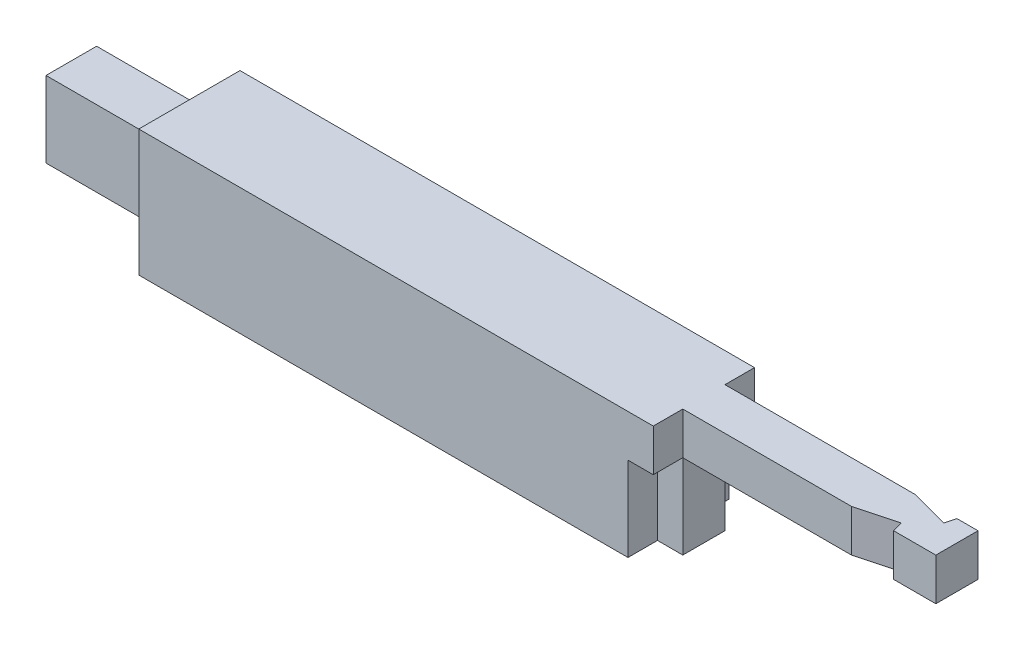
from build123d import *

# Parameters (mm, degrees)
SKETCH_1_W          = 120
SKETCH_1_H          = 150
EXTRUDE_1_DEPTH     = 610
SKETCH_2_W          = 50
SKETCH_2_H          = 50
EXTRUDE_2_DEPTH     = 300
SKETCH_3_W          = 60
SKETCH_3_H          = 90
EXTRUDE_3_DEPTH     = 140
SKETCH_4_W          = 35
SKETCH_4_H          = 100
CUT_EXTRUDE_1_DEPTH = 30
CUT_EXTRUDE_2_DEPTH = 151


with BuildPart() as part:
    # 草图1 → 凸台-拉伸1 (new body)
    with BuildSketch(Plane(origin=(0, 0, 0), x_dir=(0, 0, -1), z_dir=(1, 0, 0))):
        with Locations((60, 75)):
            Rectangle(SKETCH_1_W, SKETCH_1_H)
    extrude(amount=EXTRUDE_1_DEPTH)

    # 草图2 → 凸台-拉伸2 (add)
    with BuildSketch(Plane(origin=(610, 0, 0), x_dir=(0, 0, -1), z_dir=(1, 0, 0))):
        with Locations((60, 125)):
            Rectangle(SKETCH_2_W, SKETCH_2_H)
    extrude(amount=EXTRUDE_2_DEPTH)

    # 草图3 → 凸台-拉伸3 (add)
    with BuildSketch(Plane.ZY):
        with Locations((-60, 75)):
            Rectangle(SKETCH_3_W, SKETCH_3_H)
    extrude(amount=EXTRUDE_3_DEPTH)

    # 草图4 → 切除-拉伸1 (cut)
    with BuildSketch(Plane(origin=(610, 0, 0), x_dir=(0, 0, -1), z_dir=(1, 0, 0))):
        with Locations((17.5, 50)):
            Rectangle(SKETCH_4_W, SKETCH_4_H)
        with Locations((102.5, 50)):
            Rectangle(SKETCH_4_W, SKETCH_4_H)
    extrude(amount=-CUT_EXTRUDE_1_DEPTH, mode=Mode.SUBTRACT)

    # 草图5 → 切除-拉伸2 (cut, through all)
    with BuildSketch(Plane(origin=(0, 150, 0), x_dir=(1, 0, 0), z_dir=(0, 1, 0))):
        Polygon((810, 35), (860, 35), (856.650635095, 47.5), align=None)
        Polygon((881.650635095, 72.5), (885, 85), (835, 85), align=None)
    extrude(amount=-CUT_EXTRUDE_2_DEPTH, mode=Mode.SUBTRACT)


solid = part.part
